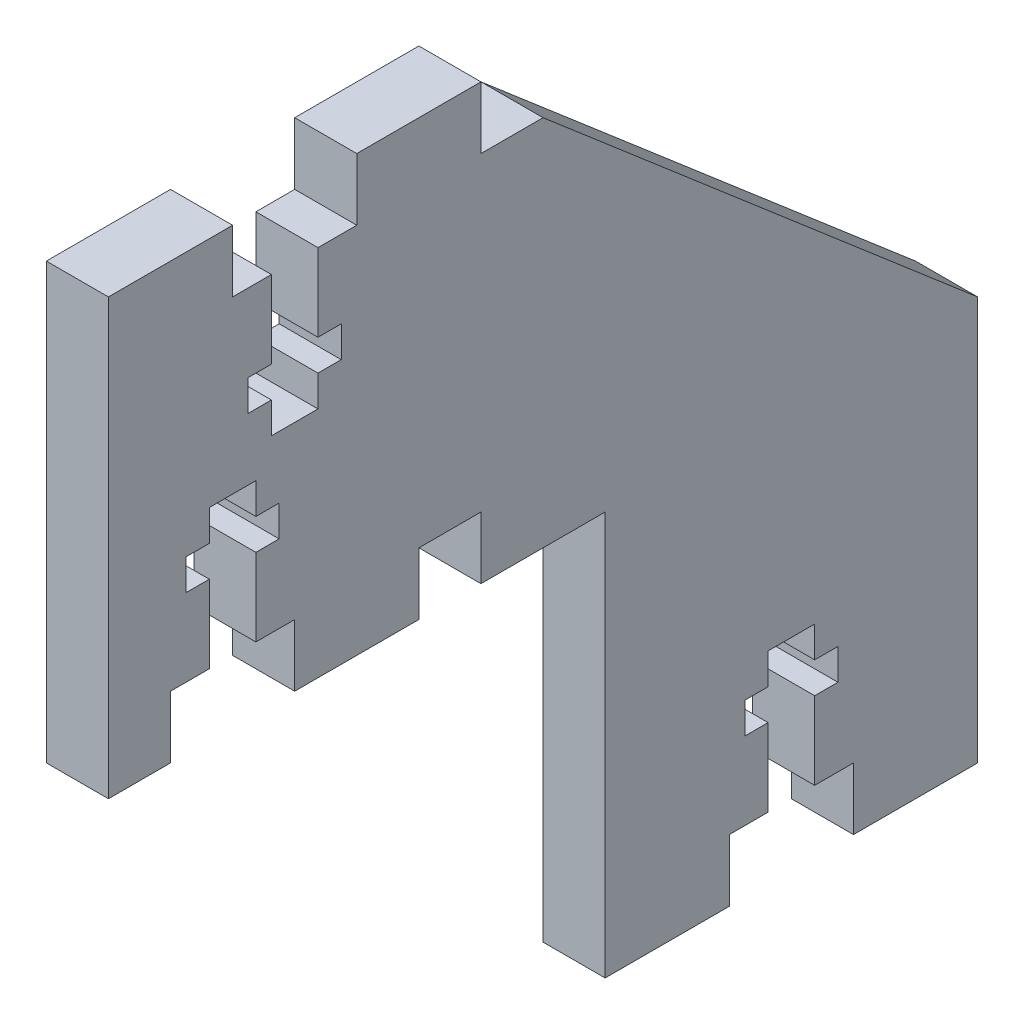
from build123d import *

# Parameters (mm, degrees)
SKETCH1_W           = 12.7
SKETCH1_H           = 6.35
SKETCH1_W_2         = 38.1
SKETCH1_H_2         = 34.925
BOSS_EXTRUDE1_DEPTH = 6.35
SKETCH2_W           = 4.7625
SKETCH2_H           = 14.2875
SKETCH2_W_2         = 9.525
SKETCH2_H_2         = 3.175
CUT_EXTRUDE1_DEPTH  = 6.35


with BuildPart() as part:
    # Sketch1 → Boss-Extrude1 (new body)
    with BuildSketch(Plane(origin=(0, 0, 0), x_dir=(0, 0, -1), z_dir=(1, 0, 0))):
        Polygon((12.7, 38.1), (12.7, 44.45), (0, 44.45), (0, 0), (6.35, 0), (6.35, 6.35), (19.05, 6.35), (19.05, 0), (31.75, 0), (31.75, 6.35), (38.1, 6.35), (38.1, 0), (44.45, 0), (44.45, 38.1), (38.1, 38.1), (38.1, 44.45), (25.4, 44.45), (25.4, 38.1), align=None)
        Polygon((88.9, 0), (44.45, 38.1), (44.45, 0), (50.8, 0), align=None)
        with Locations((57.15, -38.1)):
            Rectangle(SKETCH1_W, SKETCH1_H)
        with Locations((69.85, -17.4625)):
            Rectangle(SKETCH1_W_2, SKETCH1_H_2)
        with Locations((82.55, -38.1)):
            Rectangle(SKETCH1_W, SKETCH1_H)
    extrude(amount=BOSS_EXTRUDE1_DEPTH)

    # Sketch2 → Cut-Extrude1 (cut)
    with BuildSketch(Plane(origin=(6.35, 0, 0), x_dir=(0, 0, -1), z_dir=(1, 0, 0))):
        with Locations((12.7, 13.49375)):
            Rectangle(SKETCH2_W, SKETCH2_H)
        with Locations((12.7, 15.875)):
            Rectangle(SKETCH2_W_2, SKETCH2_H_2)
        with Locations((19.05, 30.95625)):
            Rectangle(SKETCH2_W, SKETCH2_H)
        with Locations((19.05, 28.575)):
            Rectangle(SKETCH2_W_2, SKETCH2_H_2)
        with Locations((69.85, -27.78125)):
            Rectangle(SKETCH2_W, SKETCH2_H)
        with Locations((69.85, -25.4)):
            Rectangle(SKETCH2_W_2, SKETCH2_H_2)
    extrude(amount=-CUT_EXTRUDE1_DEPTH, mode=Mode.SUBTRACT)


solid = part.part
